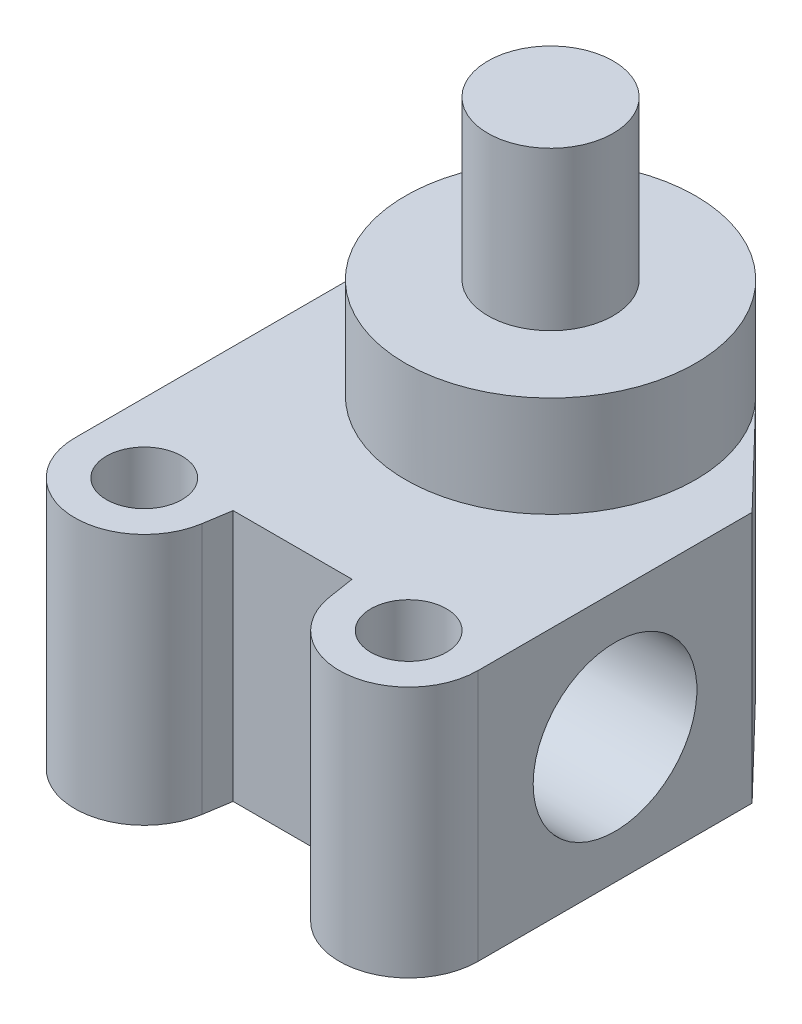
from build123d import *

# Parameters (mm, degrees)
SKETCH1_R              = 4.7625
BODY_DEPTH             = 31.75
SKETCH3_R              = 18.288
PINION_CARRIER_DEPTH   = 44.45
SKETCH4_R              = 7.8994
PINION_DEPTH           = 64.3636
SKETCH5_R              = 12.7
PINION_BOTTOM_DEPTH    = 5.8674
PINION_BOTTOM_FILLET_R = 3.81
SKETCH2_R              = 10.31875
RACK_HOLE_DEPTH        = 51.8


with BuildPart() as part:
    # Sketch1 → Body (new body)
    with BuildSketch(Plane(origin=(0, 0, 0), x_dir=(1, 0, 0), z_dir=(0, 1, 0))):
        with BuildLine():
            Line((-7.493, -32.512), (7.493, -32.512))
            Line((7.493, -32.512), (8.032785528, -35.913455304))
            ThreePointArc((8.032785528, -35.913455304), (17.349253096, -43.254561784), (25.4, -34.544))
            Line((25.4, -34.544), (25.4, 0))
            Line((25.4, 0), (13.16736, 12.691397663))
            ThreePointArc((13.16736, 12.691397663), (0, 18.288), (-13.16736, 12.691397663))
            Line((-13.16736, 12.691397663), (-25.4, 0))
            Line((-25.4, 0), (-25.4, -34.544))
            ThreePointArc((-25.4, -34.544), (-17.349253096, -43.254561784), (-8.032785528, -35.913455304))
            Line((-8.032785528, -35.913455304), (-7.493, -32.512))
        make_face()
        with Locations((16.6624, -34.544)):
            Circle(SKETCH1_R, mode=Mode.SUBTRACT)
        with Locations((-16.6624, -34.544)):
            Circle(SKETCH1_R, mode=Mode.SUBTRACT)
    extrude(amount=BODY_DEPTH)

    # Sketch3 → Pinion Carrier (add)
    with BuildSketch(Plane.XZ):
        Circle(SKETCH3_R)
    extrude(amount=-PINION_CARRIER_DEPTH)

    # Sketch4 → Pinion (add)
    with BuildSketch(Plane.XZ):
        Circle(SKETCH4_R)
    extrude(amount=-PINION_DEPTH)

    # Sketch5 → Pinion Bottom (add)
    with BuildSketch(Plane.XZ):
        Circle(SKETCH5_R)
    extrude(amount=PINION_BOTTOM_DEPTH)

    # Pinion Bottom Fillet
    pinion_bottom_fillet_edges = [part.edges().sort_by_distance(p)[0] for p in [
        (-12.7, -5.8674, 0),
    ]]
    fillet(pinion_bottom_fillet_edges, radius=PINION_BOTTOM_FILLET_R)

    # Sketch2 → Rack Hole (cut, through all)
    with BuildSketch(Plane.ZY.offset(25.4)):
        with Locations((17.272, 15.875)):
            Circle(SKETCH2_R)
    extrude(amount=-RACK_HOLE_DEPTH, mode=Mode.SUBTRACT)


solid = part.part
